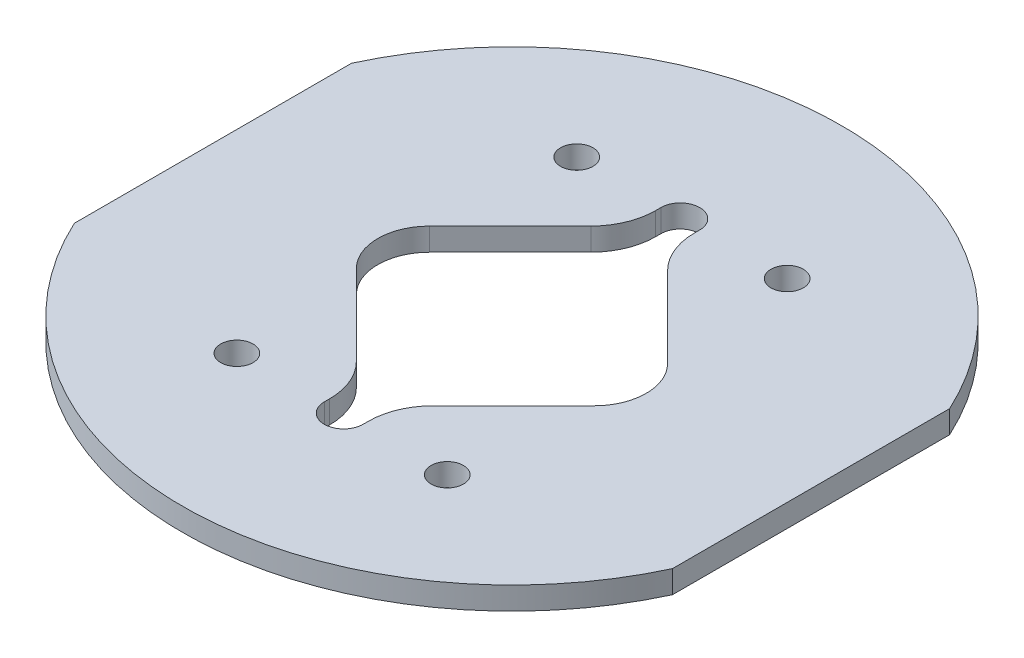
from build123d import *

# Parameters (mm, degrees)
BOSS_EXTRUDE1_DEPTH = 1.75
CUT_EXTRUDE1_DEPTH  = 2.75
CUT_EXTRUDE2_DEPTH  = 1.75
FILLET2_R           = 5
FILLET1_R           = 4
SKETCH6_R           = 1.25
CUT_EXTRUDE3_DEPTH  = 2.75
CIRPATTERN3_COUNT   = 2


with BuildPart() as part:
    # Sketch1 → Boss-Extrude1 (new body)
    with BuildSketch(Plane(origin=(0, 0, 0), x_dir=(1, 0, 0), z_dir=(0, 1, 0))):
        with BuildLine():
            Line((-23.1, -10.705213683), (-23.1, 10.705213683))
            ThreePointArc((-23.1, 10.705213683), (0, 25.46), (23.1, 10.705213683))
            Line((23.1, 10.705213683), (23.1, -10.705213683))
            ThreePointArc((23.1, -10.705213683), (0, -25.46), (-23.1, -10.705213683))
        make_face()
    extrude(amount=BOSS_EXTRUDE1_DEPTH)

    # Sketch3 → Cut-Extrude1 (cut, through all)
    with BuildSketch(Plane(origin=(0, 1.75, 0), x_dir=(1, 0, 0), z_dir=(0, 1, 0))):
        Polygon((0, -12.02081528), (-12.02081528, 0), (0, 12.02081528), (12.02081528, 0), align=None)
    extrude(amount=-CUT_EXTRUDE1_DEPTH, mode=Mode.SUBTRACT)

    # Sketch4 → Cut-Extrude2 (cut)
    with BuildSketch(Plane(origin=(0, 1.75, 0), x_dir=(1, 0, 0), z_dir=(0, 1, 0))):
        with BuildLine():
            Line((-1.5, 13), (-1.5, -13))
            ThreePointArc((-1.5, -13), (0, -14.5), (1.5, -13))
            Line((1.5, -13), (1.5, 13))
            ThreePointArc((1.5, 13), (0, 14.5), (-1.5, 13))
        make_face()
    extrude(amount=-CUT_EXTRUDE2_DEPTH, mode=Mode.SUBTRACT)

    # Fillet2
    fillet2_edges = [part.edges().sort_by_distance(p)[0] for p in [
        (1.5, 0.875, -10.52081528),
        (-1.5, 0.875, -10.52081528),
        (-1.5, 0.875, 10.52081528),
        (1.5, 0.875, 10.52081528),
    ]]
    fillet(fillet2_edges, radius=FILLET2_R)

    # Fillet1
    fillet1_edges = [part.edges().sort_by_distance(p)[0] for p in [
        (12.02081528, 0.875, 0),
        (-12.02081528, 0.875, 0),
    ]]
    fillet(fillet1_edges, radius=FILLET1_R)

    # Sketch6 → Cut-Extrude3 (cut, through all)
    with BuildSketch(Plane(origin=(0, 1.75, 0), x_dir=(1, 0, 0), z_dir=(0, 1, 0))):
        with Locations((-8.125, 13.125)):
            Circle(SKETCH6_R)
        with Locations((8.125, 13.125)):
            Circle(SKETCH6_R)
    cut_extrude3 = extrude(amount=-CUT_EXTRUDE3_DEPTH, mode=Mode.SUBTRACT)

    # CirPattern3: Cut-Extrude3 ×2 about axis
    cirpattern3_axis = Axis((0, 0, 0), (0, 1, 0))
    for i in range(1, CIRPATTERN3_COUNT):
        add(cut_extrude3.rotate(cirpattern3_axis, i * 360 / CIRPATTERN3_COUNT), mode=Mode.SUBTRACT)


solid = part.part
